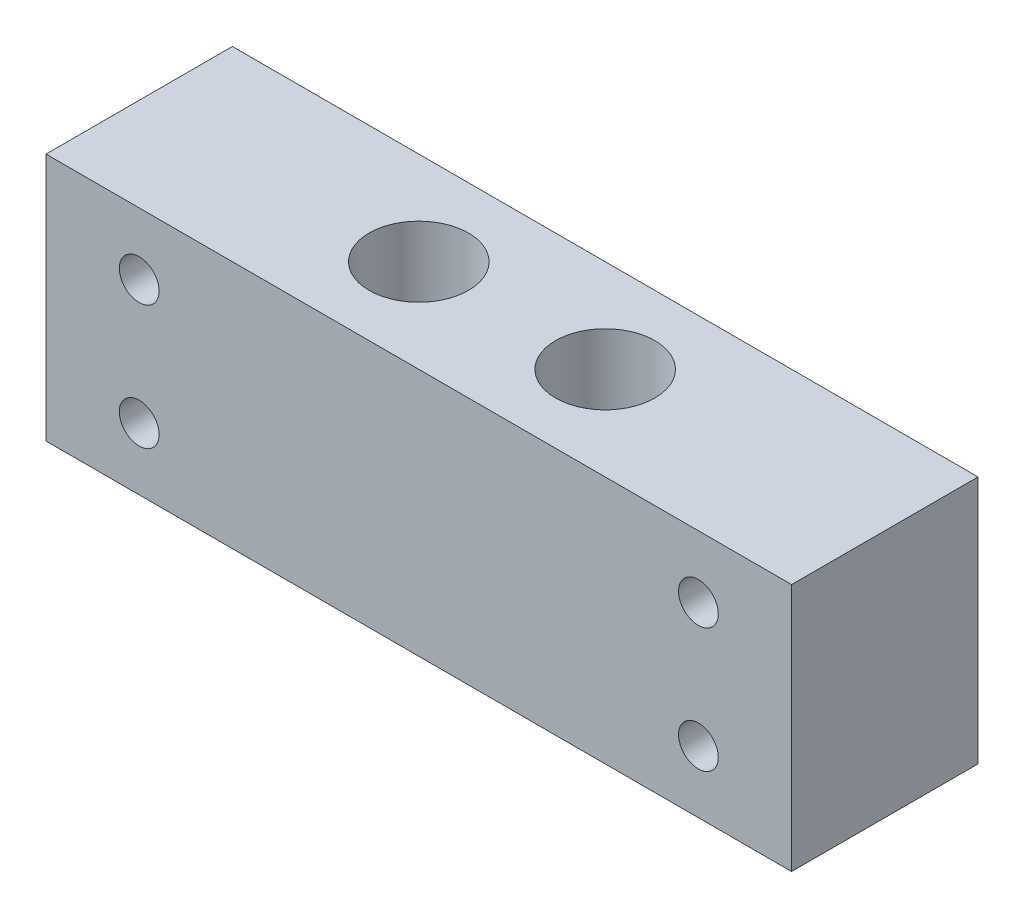
from build123d import *

# Parameters (mm, degrees)
SKETCH2_W           = 60
SKETCH2_H           = 15
SKETCH2_R           = 4
BOSS_EXTRUDE1_DEPTH = 10
SKETCH2_3_W         = 60
SKETCH2_3_H         = 15
BOSS_EXTRUDE2_DEPTH = 10
SKETCH4_R           = 1.6
CUT_EXTRUDE1_DEPTH  = 36
CUT_EXTRUDE2_START  = -6.25
SKETCH4_3_R         = 1.6
CUT_EXTRUDE2_DEPTH  = 2.5


with BuildPart() as part:
    # Sketch2 → Boss-Extrude1 (new body)
    with BuildSketch(Plane(origin=(0, 0, 0), x_dir=(1, 0, 0), z_dir=(0, 1, 0))):
        Rectangle(SKETCH2_W, SKETCH2_H)
        with Locations((-7.5, 0)):
            Circle(SKETCH2_R, mode=Mode.SUBTRACT)
        with Locations((7.5, 0)):
            Circle(SKETCH2_R, mode=Mode.SUBTRACT)
    extrude(amount=BOSS_EXTRUDE1_DEPTH)

    # Sketch2_3 → Boss-Extrude2 (add)
    with BuildSketch(Plane(origin=(0, 0, 0), x_dir=(1, 0, 0), z_dir=(0, 1, 0))):
        Rectangle(SKETCH2_3_W, SKETCH2_3_H)
    extrude(amount=-BOSS_EXTRUDE2_DEPTH)

    # Sketch4 → Cut-Extrude1 (cut, through all)
    with BuildSketch(Plane.XY.offset(7.5)):
        with Locations((22.5, 5)):
            Circle(SKETCH4_R)
        with Locations((22.5, -5)):
            Circle(SKETCH4_R)
        with Locations((-22.5, -5)):
            Circle(SKETCH4_R)
        with Locations((-22.5, 5)):
            Circle(SKETCH4_R)
    extrude(amount=-CUT_EXTRUDE1_DEPTH, mode=Mode.SUBTRACT)

    # Sketch4_3 → Cut-Extrude2 (cut)
    # profile 1 of 4: a face of its own
    with BuildSketch(Plane.XY.offset(7.5).offset(CUT_EXTRUDE2_START)):
        Polygon((-22.5, 8.435234102), (-25.475, 6.717617051), (-25.475, 3.282382949), (-22.5, 1.564765898), (-19.525, 3.282382949), (-19.525, 6.717617051), align=None)
        with Locations((-22.5, 5)):
            Circle(SKETCH4_3_R, mode=Mode.SUBTRACT)
    # profile 2 of 4: a face of its own
    with BuildSketch(Plane.XY.offset(7.5).offset(CUT_EXTRUDE2_START)):
        Polygon((22.5, 8.435234102), (19.525, 6.717617051), (19.525, 3.282382949), (22.5, 1.564765898), (25.475, 3.282382949), (25.475, 6.717617051), align=None)
        with Locations((22.5, 5)):
            Circle(SKETCH4_3_R, mode=Mode.SUBTRACT)
    # profile 3 of 4: a face of its own
    with BuildSketch(Plane.XY.offset(7.5).offset(CUT_EXTRUDE2_START)):
        Polygon((-22.5, -8.435234102), (-19.525, -6.717617051), (-19.525, -3.282382949), (-22.5, -1.564765898), (-25.475, -3.282382949), (-25.475, -6.717617051), align=None)
        with Locations((-22.5, -5)):
            Circle(SKETCH4_3_R, mode=Mode.SUBTRACT)
    # profile 4 of 4: a face of its own
    with BuildSketch(Plane.XY.offset(7.5).offset(CUT_EXTRUDE2_START)):
        Polygon((22.5, -8.435234102), (25.475, -6.717617051), (25.475, -3.282382949), (22.5, -1.564765898), (19.525, -3.282382949), (19.525, -6.717617051), align=None)
        with Locations((22.5, -5)):
            Circle(SKETCH4_3_R, mode=Mode.SUBTRACT)
    extrude(amount=-CUT_EXTRUDE2_DEPTH, mode=Mode.SUBTRACT)


solid = part.part
